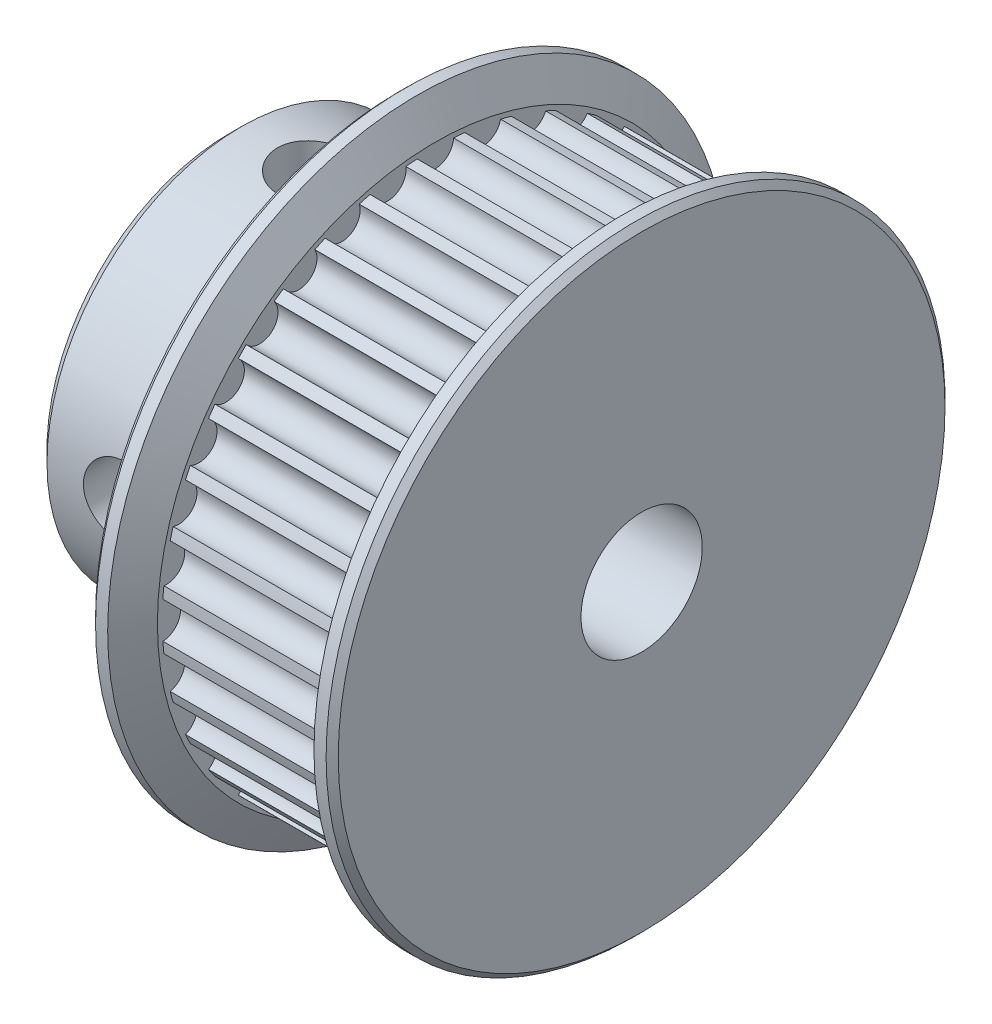
from build123d import *

# Parameters (mm, degrees)
SCHIZZO5_R               = 0.75
TAGLIO_ESTRUSIONE1_DEPTH = 7
TAGLIO_ESTRUSIONE2_REACH = 14.75
SCHIZZO6_R               = 1.5
TAGLIO_ESTRUSIONE3_REACH = 14.75
SCHIZZO7_R               = 1.5
SMUSSO1_SIZE             = 0.5
SMUSSO2_SIZE             = 0.25


with BuildPart() as part:
    # Schizzo4 → Rivoluzione1 (revolve)
    with BuildSketch(Plane.XY):
        Polygon((0, 2.5), (0, 8), (7, 8), (7, 12.75), (7.75, 12.75), (8.5, 11.450961894), (8.5, 11.25), (15.5, 11.25), (15.5, 11.450961894), (16.25, 12.75), (17, 12.75), (17, 2.5), align=None)
    revolve(axis=Axis((0, 0, 0), (1, 0, 0)))

    # Schizzo5 → Taglio-Estrusione1 (cut)
    with BuildSketch(Plane(origin=(8.5, 0, 0), x_dir=(0, 0, -1), z_dir=(1, 0, 0))):
        with Locations((0, 11.25)):
            Circle(SCHIZZO5_R)
        with Locations((1.953541999, 11.079087221)):
            Circle(SCHIZZO5_R)
        with Locations((3.847726612, 10.571541984)):
            Circle(SCHIZZO5_R)
        with Locations((5.625, 9.742785793)):
            Circle(SCHIZZO5_R)
        with Locations((7.231360609, 8.617999985)):
            Circle(SCHIZZO5_R)
        with Locations((8.617999985, 7.231360609)):
            Circle(SCHIZZO5_R)
        with Locations((9.742785793, 5.625)):
            Circle(SCHIZZO5_R)
        with Locations((10.571541984, 3.847726612)):
            Circle(SCHIZZO5_R)
        with Locations((11.079087221, 1.953541999)):
            Circle(SCHIZZO5_R)
        with Locations((11.25, 0)):
            Circle(SCHIZZO5_R)
        with Locations((11.079087221, -1.953541999)):
            Circle(SCHIZZO5_R)
        with Locations((10.571541984, -3.847726612)):
            Circle(SCHIZZO5_R)
        with Locations((9.742785793, -5.625)):
            Circle(SCHIZZO5_R)
        with Locations((8.617999985, -7.231360609)):
            Circle(SCHIZZO5_R)
        with Locations((7.231360609, -8.617999985)):
            Circle(SCHIZZO5_R)
        with Locations((5.625, -9.742785793)):
            Circle(SCHIZZO5_R)
        with Locations((3.847726612, -10.571541984)):
            Circle(SCHIZZO5_R)
        with Locations((1.953541999, -11.079087221)):
            Circle(SCHIZZO5_R)
        with Locations((0, -11.25)):
            Circle(SCHIZZO5_R)
        with Locations((-1.953541999, -11.079087221)):
            Circle(SCHIZZO5_R)
        with Locations((-3.847726612, -10.571541984)):
            Circle(SCHIZZO5_R)
        with Locations((-5.625, -9.742785793)):
            Circle(SCHIZZO5_R)
        with Locations((-7.231360609, -8.617999985)):
            Circle(SCHIZZO5_R)
        with Locations((-8.617999985, -7.231360609)):
            Circle(SCHIZZO5_R)
        with Locations((-9.742785793, -5.625)):
            Circle(SCHIZZO5_R)
        with Locations((-10.571541984, -3.847726612)):
            Circle(SCHIZZO5_R)
        with Locations((-11.079087221, -1.953541999)):
            Circle(SCHIZZO5_R)
        with Locations((-11.25, 0)):
            Circle(SCHIZZO5_R)
        with Locations((-11.079087221, 1.953541999)):
            Circle(SCHIZZO5_R)
        with Locations((-10.571541984, 3.847726612)):
            Circle(SCHIZZO5_R)
        with Locations((-9.742785793, 5.625)):
            Circle(SCHIZZO5_R)
        with Locations((-8.617999985, 7.231360609)):
            Circle(SCHIZZO5_R)
        with Locations((-7.231360609, 8.617999985)):
            Circle(SCHIZZO5_R)
        with Locations((-5.625, 9.742785793)):
            Circle(SCHIZZO5_R)
        with Locations((-3.847726612, 10.571541984)):
            Circle(SCHIZZO5_R)
        with Locations((-1.953541999, 11.079087221)):
            Circle(SCHIZZO5_R)
    extrude(amount=TAGLIO_ESTRUSIONE1_DEPTH, mode=Mode.SUBTRACT)

    # Schizzo6 → Taglio-Estrusione2 (cut, up to next)
    with BuildSketch(Plane.XY, mode=Mode.PRIVATE) as taglio_estrusione2_sk1:
        with Locations((3.5, 0)):
            Circle(SCHIZZO6_R)
    taglio_estrusione2_tool1 = extrude(taglio_estrusione2_sk1.sketch, amount=TAGLIO_ESTRUSIONE2_REACH, mode=Mode.PRIVATE) & part.part
    add(taglio_estrusione2_tool1.solids().sort_by_distance((3.5, 0, 0))[0], mode=Mode.SUBTRACT)

    # Schizzo7 → Taglio-Estrusione3 (cut, up to next)
    with BuildSketch(Plane(origin=(0, 0, 0), x_dir=(1, 0, 0), z_dir=(0, 1, 0)), mode=Mode.PRIVATE) as taglio_estrusione3_sk1:
        with Locations((3.5, 0)):
            Circle(SCHIZZO7_R)
    taglio_estrusione3_tool1 = extrude(taglio_estrusione3_sk1.sketch, amount=TAGLIO_ESTRUSIONE3_REACH, mode=Mode.PRIVATE) & part.part
    add(taglio_estrusione3_tool1.solids().sort_by_distance((3.5, 0, 0))[0], mode=Mode.SUBTRACT)

    # Smusso1
    smusso1_edges = [part.edges().sort_by_distance(p)[0] for p in [
        (0, -8, 0),
        (0, -2.5, 0),
    ]]
    chamfer(smusso1_edges, length=SMUSSO1_SIZE)

    # Smusso2
    smusso2_edges = [part.edges().sort_by_distance(p)[0] for p in [
        (7, -12.75, 0),
        (17, -12.75, 0),
    ]]
    chamfer(smusso2_edges, length=SMUSSO2_SIZE)


solid = part.part
